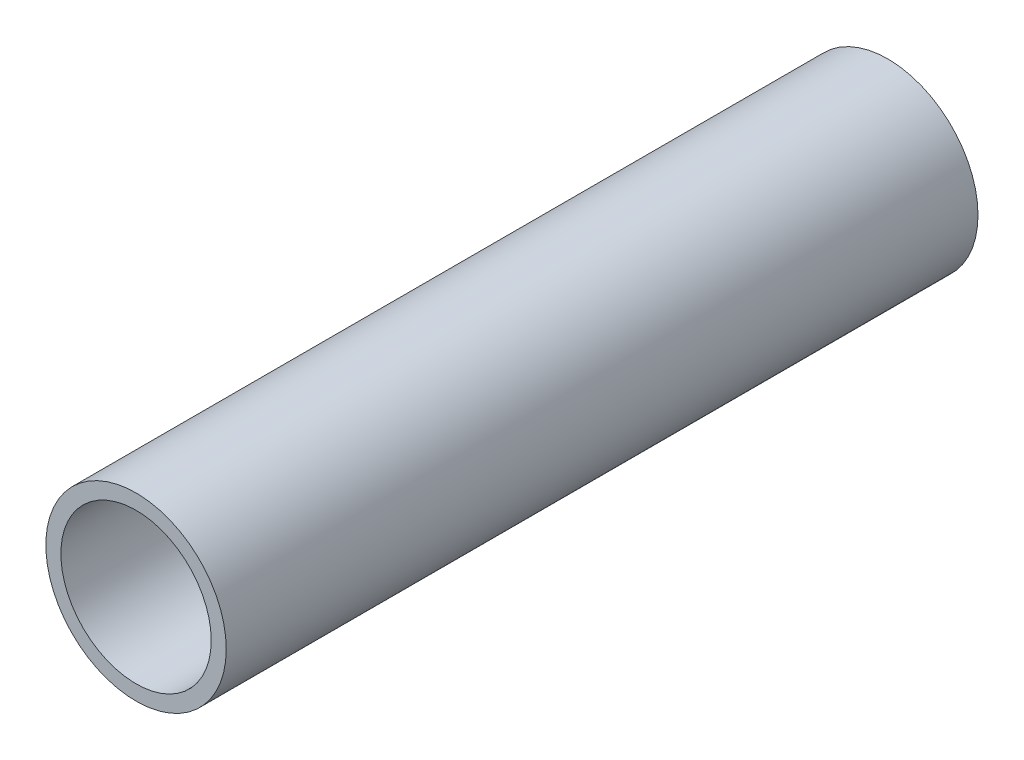
from build123d import *

# Parameters (mm, degrees)
SKETCH_1_R      = 60
SKETCH_1_R_2    = 50
EXTRUDE_1_DEPTH = 500


with BuildPart() as part:
    # Эскиз1 → Бобышка-Вытянуть1 (new body)
    with BuildSketch(Plane.XY):
        Circle(SKETCH_1_R)
        Circle(SKETCH_1_R_2, mode=Mode.SUBTRACT)
    extrude(amount=EXTRUDE_1_DEPTH)


solid = part.part
